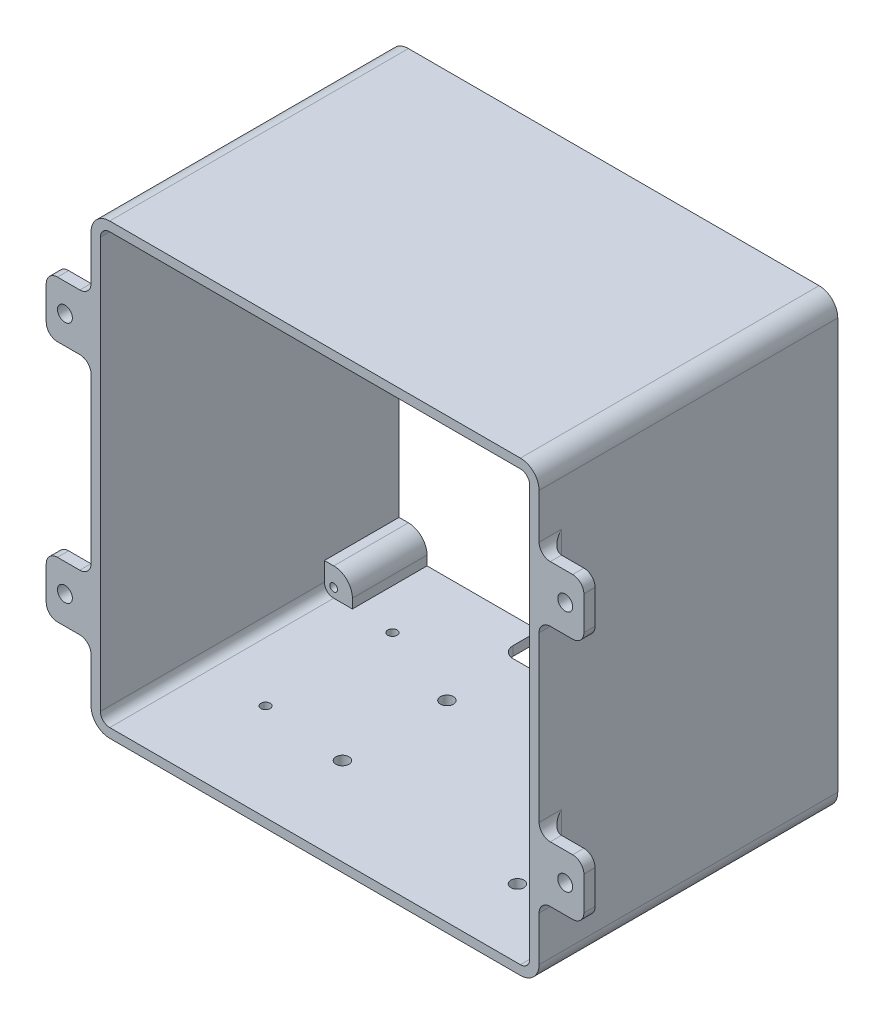
from build123d import *

# Parameters (mm, degrees)
EXTRUDE_THIN1_DEPTH            = 80
BOSS_EXTRUDE2_DEPTH            = 20
SKETCH3_R                      = 1.75
SKETCH3_R_2                    = 1.7500092
SKETCH3_R_3                    = 1.25
CUT_EXTRUDE1_DEPTH             = 10
CUT_EXTRUDE2_REACH             = 122
SKETCH6_R                      = 2
BOSS_EXTRUDE3_DEPTH            = 3
FILLET1_R                      = 3
FILLET2_R                      = 3
TAP_DRILL_FOR_M2_5X0_45_TAP1_D = 2.05


with BuildPart() as part:
    # Sketch1 → Extrude-Thin1 (new body)
    with BuildSketch(Plane.XY):
        with BuildLine():
            Line((29, 86), (-81, 86))
            ThreePointArc((-81, 86), (-84.535533906, 84.535533906), (-86, 81))
            Line((-86, 81), (-86, -29))
            ThreePointArc((-86, -29), (-84.535533906, -32.535533906), (-81, -34))
            Line((-81, -34), (29, -34))
            ThreePointArc((29, -34), (32.535533906, -32.535533906), (34, -29))
            Line((34, -29), (34, 81))
            ThreePointArc((34, 81), (32.535533906, 84.535533906), (29, 86))
        make_face()
        with BuildLine():
            Line((29, 83.5), (-81, 83.5))
            ThreePointArc((-81, 83.5), (-82.767766953, 82.767766953), (-83.5, 81))
            Line((-83.5, 81), (-83.5, -29))
            ThreePointArc((-83.5, -29), (-82.767766953, -30.767766953), (-81, -31.5))
            Line((-81, -31.5), (29, -31.5))
            ThreePointArc((29, -31.5), (30.767766953, -30.767766953), (31.5, -29))
            Line((31.5, -29), (31.5, 81))
            ThreePointArc((31.5, 81), (30.767766953, 82.767766953), (29, 83.5))
        make_face(mode=Mode.SUBTRACT)
    extrude(amount=EXTRUDE_THIN1_DEPTH)

    # Sketch2 → Boss-Extrude2 (add)
    with BuildSketch(Plane.XY):
        with BuildLine():
            Line((29, -24), (31.5, -24))
            Line((31.5, -24), (31.5, -29))
            ThreePointArc((31.5, -29), (30.767766953, -30.767766953), (29, -31.5))
            Line((29, -31.5), (24, -31.5))
            Line((24, -31.5), (24, -29))
            ThreePointArc((24, -29), (25.464466094, -25.464466094), (29, -24))
        make_face()
        with BuildLine():
            Line((-76, -29), (-76, -31.5))
            Line((-76, -31.5), (-81, -31.5))
            ThreePointArc((-81, -31.5), (-82.767766953, -30.767766953), (-83.5, -29))
            Line((-83.5, -29), (-83.5, -24))
            Line((-83.5, -24), (-81, -24))
            ThreePointArc((-81, -24), (-77.464466094, -25.464466094), (-76, -29))
        make_face()
        with BuildLine():
            Line((-81, 76), (-83.5, 76))
            Line((-83.5, 76), (-83.5, 81))
            ThreePointArc((-83.5, 81), (-82.767766953, 82.767766953), (-81, 83.5))
            Line((-81, 83.5), (-76, 83.5))
            Line((-76, 83.5), (-76, 81))
            ThreePointArc((-76, 81), (-77.464466094, 77.464466094), (-81, 76))
        make_face()
        with BuildLine():
            Line((24, 81), (24, 83.5))
            Line((24, 83.5), (29, 83.5))
            ThreePointArc((29, 83.5), (30.767766953, 82.767766953), (31.5, 81))
            Line((31.5, 81), (31.5, 76))
            Line((31.5, 76), (29, 76))
            ThreePointArc((29, 76), (25.464466094, 77.464466094), (24, 81))
        make_face()
    extrude(amount=BOSS_EXTRUDE2_DEPTH)

    # Sketch3 → Cut-Extrude1 (cut)
    with BuildSketch(Plane.XZ.offset(34)):
        with Locations((9.866177282, 61.657658655)):
            Circle(SKETCH3_R)
        with Locations((8.690958198, 13.395257553)):
            Circle(SKETCH3_R)
        with Locations((-42.193745622, 56.475407474)):
            Circle(SKETCH3_R_2)
        with Locations((-42.138873878, 28.535461355)):
            Circle(SKETCH3_R_2)
        with Locations((-65.153703669, 54.105224901)):
            Circle(SKETCH3_R_3)
        with Locations((-65.153703669, 20.105224901)):
            Circle(SKETCH3_R_3)
    extrude(amount=-CUT_EXTRUDE1_DEPTH, mode=Mode.SUBTRACT)

    # Sketch4 → Cut-Extrude2 (cut, up to next)
    with BuildSketch(Plane.XZ.offset(34), mode=Mode.PRIVATE) as cut_extrude2_sk1:
        with BuildLine():
            Line((-6, 0), (-46, 0))
            Line((-46, 0), (-46, 7))
            ThreePointArc((-46, 7), (-45.121320344, 9.121320344), (-43, 10))
            Line((-43, 10), (-9, 10))
            ThreePointArc((-9, 10), (-6.878679656, 9.121320344), (-6, 7))
            Line((-6, 7), (-6, 0))
        make_face()
    cut_extrude2_tool1 = extrude(cut_extrude2_sk1.sketch, amount=-CUT_EXTRUDE2_REACH, mode=Mode.PRIVATE) & part.part
    add(cut_extrude2_tool1.solids().sort_by_distance((-26, -34, 4.957778))[0], mode=Mode.SUBTRACT)

    # Sketch6 → Boss-Extrude3 (add)
    with BuildSketch(Plane.XY.offset(80)):
        with BuildLine():
            Line((-86, -14), (-86, 1))
            Line((-86, 1), (-95, 1))
            ThreePointArc((-95, 1), (-97.121320344, 0.121320344), (-98, -2))
            Line((-98, -2), (-98, -11))
            ThreePointArc((-98, -11), (-97.121320344, -13.121320344), (-95, -14))
            Line((-95, -14), (-86, -14))
        make_face()
        with Locations((-93, -6.5)):
            Circle(SKETCH6_R, mode=Mode.SUBTRACT)
        with BuildLine():
            Line((43, 1), (34, 1))
            Line((34, 1), (34, -14))
            Line((34, -14), (43, -14))
            ThreePointArc((43, -14), (45.121320344, -13.121320344), (46, -11))
            Line((46, -11), (46, -2))
            ThreePointArc((46, -2), (45.121320344, 0.121320344), (43, 1))
        make_face()
        with Locations((41, -6.5)):
            Circle(SKETCH6_R, mode=Mode.SUBTRACT)
        with BuildLine():
            Line((46, 54), (46, 63))
            ThreePointArc((46, 63), (45.121320344, 65.121320344), (43, 66))
            Line((43, 66), (34, 66))
            Line((34, 66), (34, 51))
            Line((34, 51), (43, 51))
            ThreePointArc((43, 51), (45.121320344, 51.878679656), (46, 54))
        make_face()
        with Locations((41, 58.5)):
            Circle(SKETCH6_R, mode=Mode.SUBTRACT)
        with BuildLine():
            Line((-86, 51), (-86, 66))
            Line((-86, 66), (-95, 66))
            ThreePointArc((-95, 66), (-97.121320344, 65.121320344), (-98, 63))
            Line((-98, 63), (-98, 54))
            ThreePointArc((-98, 54), (-97.121320344, 51.878679656), (-95, 51))
            Line((-95, 51), (-86, 51))
        make_face()
        with Locations((-93, 58.5)):
            Circle(SKETCH6_R, mode=Mode.SUBTRACT)
    extrude(amount=-BOSS_EXTRUDE3_DEPTH)

    # Fillet1
    fillet1_edges = [part.edges().sort_by_distance(p)[0] for p in [
        (-86, 1, 78.5),
        (-86, -14, 78.5),
        (34, -14, 78.5),
        (34, 1, 78.5),
        (34, 51, 78.5),
        (34, 66, 78.5),
        (-86, 66, 78.5),
        (-86, 51, 78.5),
    ]]
    fillet(fillet1_edges, radius=FILLET1_R)

    # Fillet2
    fillet2_edges = [part.edges().sort_by_distance(p)[0] for p in [
        (34, 58.5, 77),
        (34, -6.5, 77),
        (-86, 58.5, 77),
        (-86, -6.5, 77),
    ]]
    fillet(fillet2_edges, radius=FILLET2_R)

    # Tap Drill for M2.5x0.45 Tap1 (through all)
    with Locations(Plane(origin=(0, 0, 0), x_dir=(-1, 0, 0), z_dir=(0, 0, -1))):
        with Locations((81, -29), (81, 81), (-29, -29), (-29, 81)):
            Hole(TAP_DRILL_FOR_M2_5X0_45_TAP1_D / 2)


solid = part.part
